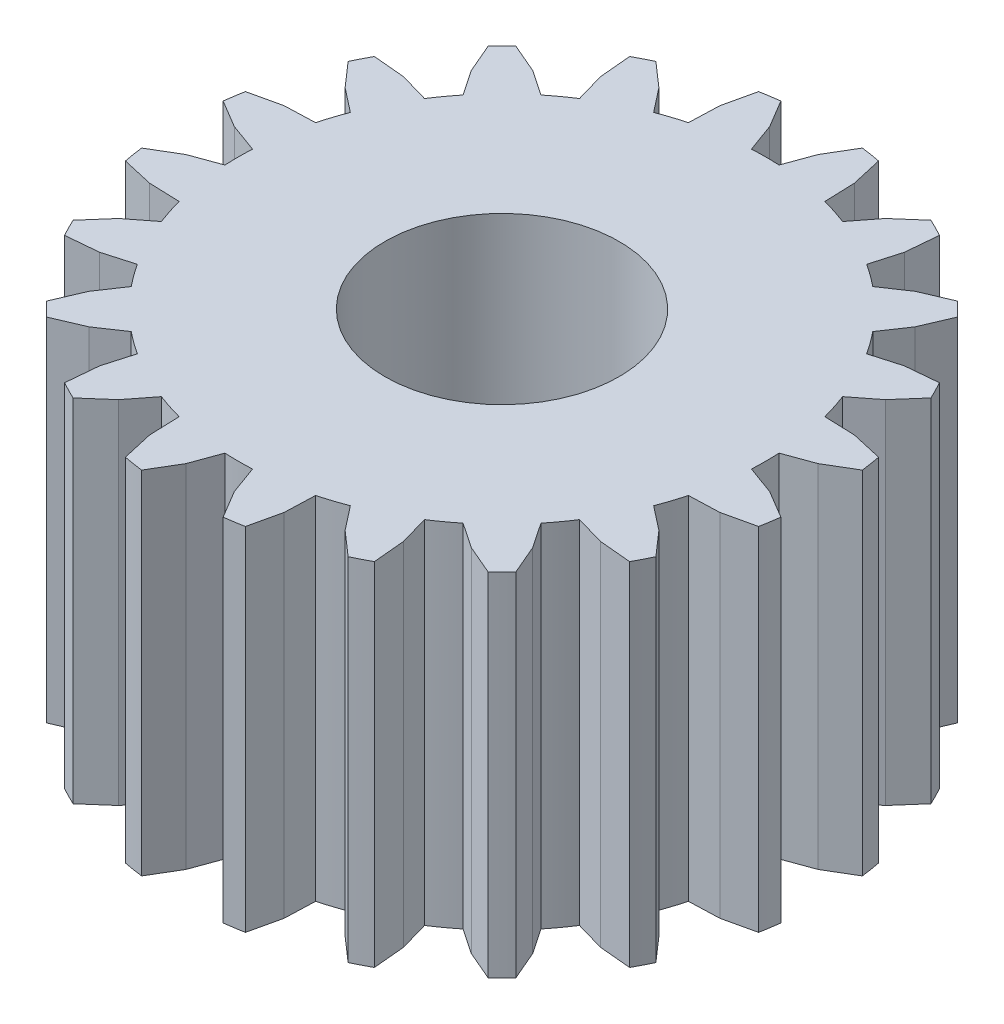
from build123d import *

# Parameters (mm, degrees)
IZIM2_R                     = 1
Y_KSEKLIK_EKSTR_ZYON1_DEPTH = 3


with BuildPart() as part:
    # Çizim2 → Yükseklik-Ekstrüzyon1 (new body)
    with BuildSketch(Plane(origin=(0, 0, 0), x_dir=(1, 0, 0), z_dir=(0, 1, 0))):
        with BuildLine():
            Line((2.727931774, -0.347689854), (2.491435912, -0.206753706))
            Line((2.491435912, -0.206753706), (2.246916453, -0.117755902))
            ThreePointArc((2.246916453, -0.117755902), (2.25, 0), (2.246916453, 0.117755902))
            Line((2.246916453, 0.117755902), (2.491435912, 0.206753706))
            Line((2.491435912, 0.206753706), (2.727931774, 0.347689854))
            ThreePointArc((2.727931774, 0.347689854), (2.716142937, 0.430194779), (2.701859364, 0.512304577))
            Line((2.701859364, 0.512304577), (2.433386768, 0.573261578))
            Line((2.433386768, 0.573261578), (2.173333109, 0.582342851))
            ThreePointArc((2.173333109, 0.582342851), (2.139877162, 0.695288237), (2.10055596, 0.806327886))
            Line((2.10055596, 0.806327886), (2.30560595, 0.966530497))
            Line((2.30560595, 0.966530497), (2.486975217, 1.173649979))
            ThreePointArc((2.486975217, 1.173649979), (2.450267942, 1.248473874), (2.411310133, 1.322151066))
            Line((2.411310133, 1.322151066), (2.137140773, 1.297162024))
            Line((2.137140773, 1.297162024), (1.887008778, 1.225437829))
            ThreePointArc((1.887008778, 1.225437829), (1.820288237, 1.322516818), (1.748578413, 1.41597088))
            Line((1.748578413, 1.41597088), (1.894087214, 1.631696548))
            Line((1.894087214, 1.631696548), (2.002576197, 1.884725067))
            ThreePointArc((2.002576197, 1.884725067), (1.944543648, 1.944543648), (1.884725067, 2.002576197))
            Line((1.884725067, 2.002576197), (1.631696548, 1.894087214))
            Line((1.631696548, 1.894087214), (1.41597088, 1.748578413))
            ThreePointArc((1.41597088, 1.748578413), (1.322516818, 1.820288237), (1.225437829, 1.887008778))
            Line((1.225437829, 1.887008778), (1.297162024, 2.137140773))
            Line((1.297162024, 2.137140773), (1.322151066, 2.411310133))
            ThreePointArc((1.322151066, 2.411310133), (1.248473874, 2.450267942), (1.173649979, 2.486975217))
            Line((1.173649979, 2.486975217), (0.966530497, 2.30560595))
            Line((0.966530497, 2.30560595), (0.806327886, 2.10055596))
            ThreePointArc((0.806327886, 2.10055596), (0.695288237, 2.139877162), (0.582342851, 2.173333109))
            Line((0.582342851, 2.173333109), (0.573261578, 2.433386768))
            Line((0.573261578, 2.433386768), (0.512304577, 2.701859364))
            ThreePointArc((0.512304577, 2.701859364), (0.430194779, 2.716142937), (0.347689854, 2.727931774))
            Line((0.347689854, 2.727931774), (0.206753706, 2.491435912))
            Line((0.206753706, 2.491435912), (0.117755902, 2.246916453))
            ThreePointArc((0.117755902, 2.246916453), (0, 2.25), (-0.117755902, 2.246916453))
            Line((-0.117755902, 2.246916453), (-0.206753706, 2.491435912))
            Line((-0.206753706, 2.491435912), (-0.347689854, 2.727931774))
            ThreePointArc((-0.347689854, 2.727931774), (-0.430194779, 2.716142937), (-0.512304577, 2.701859364))
            Line((-0.512304577, 2.701859364), (-0.573261578, 2.433386768))
            Line((-0.573261578, 2.433386768), (-0.582342851, 2.173333109))
            ThreePointArc((-0.582342851, 2.173333109), (-0.695288237, 2.139877162), (-0.806327886, 2.10055596))
            Line((-0.806327886, 2.10055596), (-0.966530497, 2.30560595))
            Line((-0.966530497, 2.30560595), (-1.173649979, 2.486975217))
            ThreePointArc((-1.173649979, 2.486975217), (-1.248473874, 2.450267942), (-1.322151066, 2.411310133))
            Line((-1.322151066, 2.411310133), (-1.297162024, 2.137140773))
            Line((-1.297162024, 2.137140773), (-1.225437829, 1.887008778))
            ThreePointArc((-1.225437829, 1.887008778), (-1.322516818, 1.820288237), (-1.41597088, 1.748578413))
            Line((-1.41597088, 1.748578413), (-1.631696548, 1.894087214))
            Line((-1.631696548, 1.894087214), (-1.884725067, 2.002576197))
            ThreePointArc((-1.884725067, 2.002576197), (-1.944543648, 1.944543648), (-2.002576197, 1.884725067))
            Line((-2.002576197, 1.884725067), (-1.894087214, 1.631696548))
            Line((-1.894087214, 1.631696548), (-1.748578413, 1.41597088))
            ThreePointArc((-1.748578413, 1.41597088), (-1.820288237, 1.322516818), (-1.887008778, 1.225437829))
            Line((-1.887008778, 1.225437829), (-2.137140773, 1.297162024))
            Line((-2.137140773, 1.297162024), (-2.411310133, 1.322151066))
            ThreePointArc((-2.411310133, 1.322151066), (-2.450267942, 1.248473874), (-2.486975217, 1.173649979))
            Line((-2.486975217, 1.173649979), (-2.30560595, 0.966530497))
            Line((-2.30560595, 0.966530497), (-2.10055596, 0.806327886))
            ThreePointArc((-2.10055596, 0.806327886), (-2.139877162, 0.695288237), (-2.173333109, 0.582342851))
            Line((-2.173333109, 0.582342851), (-2.433386768, 0.573261578))
            Line((-2.433386768, 0.573261578), (-2.701859364, 0.512304577))
            ThreePointArc((-2.701859364, 0.512304577), (-2.716142937, 0.430194779), (-2.727931774, 0.347689854))
            Line((-2.727931774, 0.347689854), (-2.491435912, 0.206753706))
            Line((-2.491435912, 0.206753706), (-2.246916453, 0.117755902))
            ThreePointArc((-2.246916453, 0.117755902), (-2.25, 0), (-2.246916453, -0.117755902))
            Line((-2.246916453, -0.117755902), (-2.491435912, -0.206753706))
            Line((-2.491435912, -0.206753706), (-2.727931774, -0.347689854))
            ThreePointArc((-2.727931774, -0.347689854), (-2.716142937, -0.430194779), (-2.701859364, -0.512304577))
            Line((-2.701859364, -0.512304577), (-2.433386768, -0.573261578))
            Line((-2.433386768, -0.573261578), (-2.173333109, -0.582342851))
            ThreePointArc((-2.173333109, -0.582342851), (-2.139877162, -0.695288237), (-2.10055596, -0.806327886))
            Line((-2.10055596, -0.806327886), (-2.30560595, -0.966530497))
            Line((-2.30560595, -0.966530497), (-2.486975217, -1.173649979))
            ThreePointArc((-2.486975217, -1.173649979), (-2.450267942, -1.248473874), (-2.411310133, -1.322151066))
            Line((-2.411310133, -1.322151066), (-2.137140773, -1.297162024))
            Line((-2.137140773, -1.297162024), (-1.887008778, -1.225437829))
            ThreePointArc((-1.887008778, -1.225437829), (-1.820288237, -1.322516818), (-1.748578413, -1.41597088))
            Line((-1.748578413, -1.41597088), (-1.894087214, -1.631696548))
            Line((-1.894087214, -1.631696548), (-2.002576197, -1.884725067))
            ThreePointArc((-2.002576197, -1.884725067), (-1.944543648, -1.944543648), (-1.884725067, -2.002576197))
            Line((-1.884725067, -2.002576197), (-1.631696548, -1.894087214))
            Line((-1.631696548, -1.894087214), (-1.41597088, -1.748578413))
            ThreePointArc((-1.41597088, -1.748578413), (-1.322516818, -1.820288237), (-1.225437829, -1.887008778))
            Line((-1.225437829, -1.887008778), (-1.297162024, -2.137140773))
            Line((-1.297162024, -2.137140773), (-1.322151066, -2.411310133))
            ThreePointArc((-1.322151066, -2.411310133), (-1.248473874, -2.450267942), (-1.173649979, -2.486975217))
            Line((-1.173649979, -2.486975217), (-0.966530497, -2.30560595))
            Line((-0.966530497, -2.30560595), (-0.806327886, -2.10055596))
            ThreePointArc((-0.806327886, -2.10055596), (-0.695288237, -2.139877162), (-0.582342851, -2.173333109))
            Line((-0.582342851, -2.173333109), (-0.573261578, -2.433386768))
            Line((-0.573261578, -2.433386768), (-0.512304577, -2.701859364))
            ThreePointArc((-0.512304577, -2.701859364), (-0.430194779, -2.716142937), (-0.347689854, -2.727931774))
            Line((-0.347689854, -2.727931774), (-0.206753706, -2.491435912))
            Line((-0.206753706, -2.491435912), (-0.117755902, -2.246916453))
            ThreePointArc((-0.117755902, -2.246916453), (0, -2.25), (0.117755902, -2.246916453))
            Line((0.117755902, -2.246916453), (0.206753706, -2.491435912))
            Line((0.206753706, -2.491435912), (0.347689854, -2.727931774))
            ThreePointArc((0.347689854, -2.727931774), (0.430194779, -2.716142937), (0.512304577, -2.701859364))
            Line((0.512304577, -2.701859364), (0.573261578, -2.433386768))
            Line((0.573261578, -2.433386768), (0.582342851, -2.173333109))
            ThreePointArc((0.582342851, -2.173333109), (0.695288237, -2.139877162), (0.806327886, -2.10055596))
            Line((0.806327886, -2.10055596), (0.966530497, -2.30560595))
            Line((0.966530497, -2.30560595), (1.173649979, -2.486975217))
            ThreePointArc((1.173649979, -2.486975217), (1.248473874, -2.450267942), (1.322151066, -2.411310133))
            Line((1.322151066, -2.411310133), (1.297162024, -2.137140773))
            Line((1.297162024, -2.137140773), (1.225437829, -1.887008778))
            ThreePointArc((1.225437829, -1.887008778), (1.322516818, -1.820288237), (1.41597088, -1.748578413))
            Line((1.41597088, -1.748578413), (1.631696548, -1.894087214))
            Line((1.631696548, -1.894087214), (1.884725067, -2.002576197))
            ThreePointArc((1.884725067, -2.002576197), (1.944543648, -1.944543648), (2.002576197, -1.884725067))
            Line((2.002576197, -1.884725067), (1.894087214, -1.631696548))
            Line((1.894087214, -1.631696548), (1.748578413, -1.41597088))
            ThreePointArc((1.748578413, -1.41597088), (1.820288237, -1.322516818), (1.887008778, -1.225437829))
            Line((1.887008778, -1.225437829), (2.137140773, -1.297162024))
            Line((2.137140773, -1.297162024), (2.411310133, -1.322151066))
            ThreePointArc((2.411310133, -1.322151066), (2.450267942, -1.248473874), (2.486975217, -1.173649979))
            Line((2.486975217, -1.173649979), (2.30560595, -0.966530497))
            Line((2.30560595, -0.966530497), (2.10055596, -0.806327886))
            ThreePointArc((2.10055596, -0.806327886), (2.139877162, -0.695288237), (2.173333109, -0.582342851))
            Line((2.173333109, -0.582342851), (2.433386768, -0.573261578))
            Line((2.433386768, -0.573261578), (2.701859364, -0.512304577))
            ThreePointArc((2.701859364, -0.512304577), (2.716142937, -0.430194779), (2.727931774, -0.347689854))
        make_face()
        Circle(IZIM2_R, mode=Mode.SUBTRACT)
    extrude(amount=Y_KSEKLIK_EKSTR_ZYON1_DEPTH)


solid = part.part
